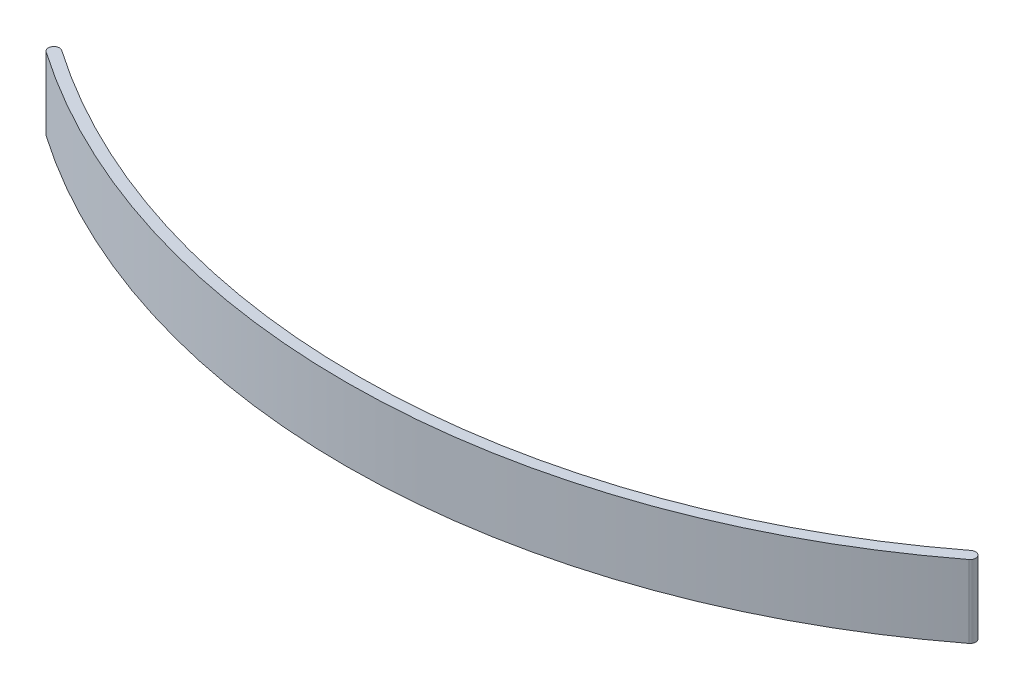
from build123d import *

# Parameters (mm, degrees)
BOSS_EXTRUDE1_DEPTH = 6.5


with BuildPart() as part:
    # Sketch1 → Boss-Extrude1 (new body)
    with BuildSketch(Plane(origin=(0, 0, 0), x_dir=(1, 0, 0), z_dir=(0, 1, 0))):
        with BuildLine():
            ThreePointArc((-40.588860661, 11.650035695), (0.012118342, -0.499853124), (39.976624921, 13.603249661))
            ThreePointArc((39.976624921, 13.603249661), (40.069090576, 14.304284684), (39.368055554, 14.396750339))
            ThreePointArc((39.368055554, 14.396750339), (-0.012118342, 0.499853124), (-40.019458613, 12.472094882))
            ThreePointArc((-40.019458613, 12.472094882), (-40.715189231, 12.345766313), (-40.588860661, 11.650035695))
        make_face()
    extrude(amount=BOSS_EXTRUDE1_DEPTH)


solid = part.part
